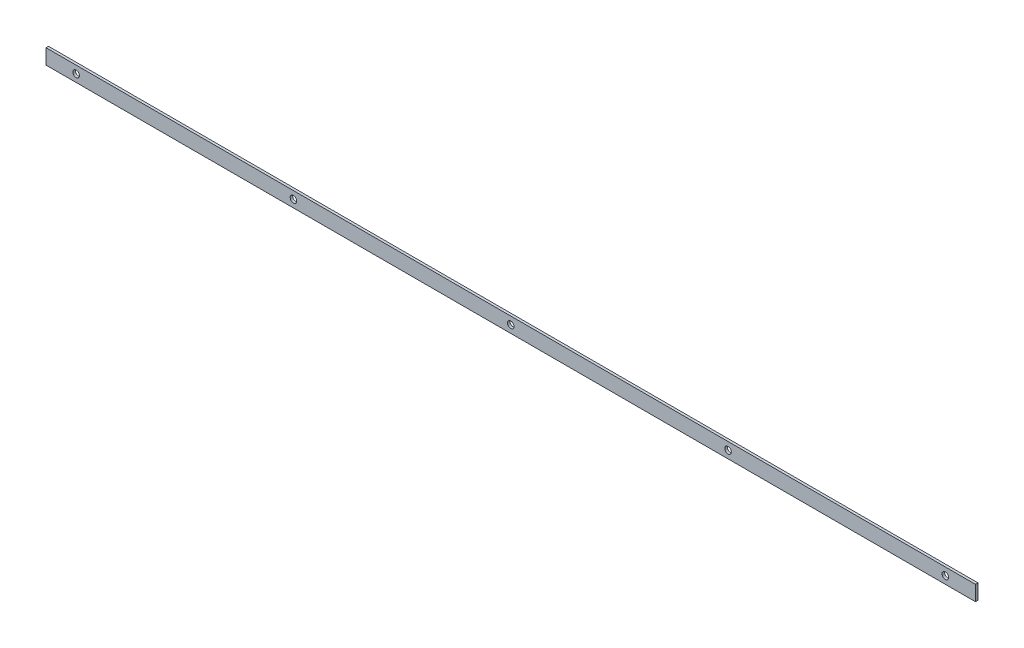
from build123d import *

# Parameters (mm, degrees)
PLAT_W                          = 30
PLAT_H                          = 5
EL_MENT_M_CANO_SOUD_1_DEPTH     = 1850
DIAM_TRE_DU_PER_AGE_13_0_13_1_D = 13
R_P_TITION_LIN_AIRE2_COUNT      = 5
R_P_TITION_LIN_AIRE2_PITCH      = 432.5


with BuildPart() as part:
    # plat → Elément mécano-soudé1 (new body)
    with BuildSketch(Plane.YZ.offset(-925)):
        Rectangle(PLAT_W, PLAT_H)
    extrude(amount=EL_MENT_M_CANO_SOUD_1_DEPTH)

    # Diamètre du perçage Ø13.0 (13)1 (through all)
    with Locations(Plane(origin=(0, 0, -2.5), x_dir=(-1, 0, 0), z_dir=(0, 0, -1))):
        with Locations((865, 0)):
            diam_tre_du_per_age_13_0_13_1 = Hole(DIAM_TRE_DU_PER_AGE_13_0_13_1_D / 2)

    # Répétition linéaire2: Diamètre du perçage Ø13.0 (13)1 ×5
    with Locations(*[(i * R_P_TITION_LIN_AIRE2_PITCH, 0, 0) for i in range(1, R_P_TITION_LIN_AIRE2_COUNT)]):
        add(diam_tre_du_per_age_13_0_13_1, mode=Mode.SUBTRACT)


solid = part.part
